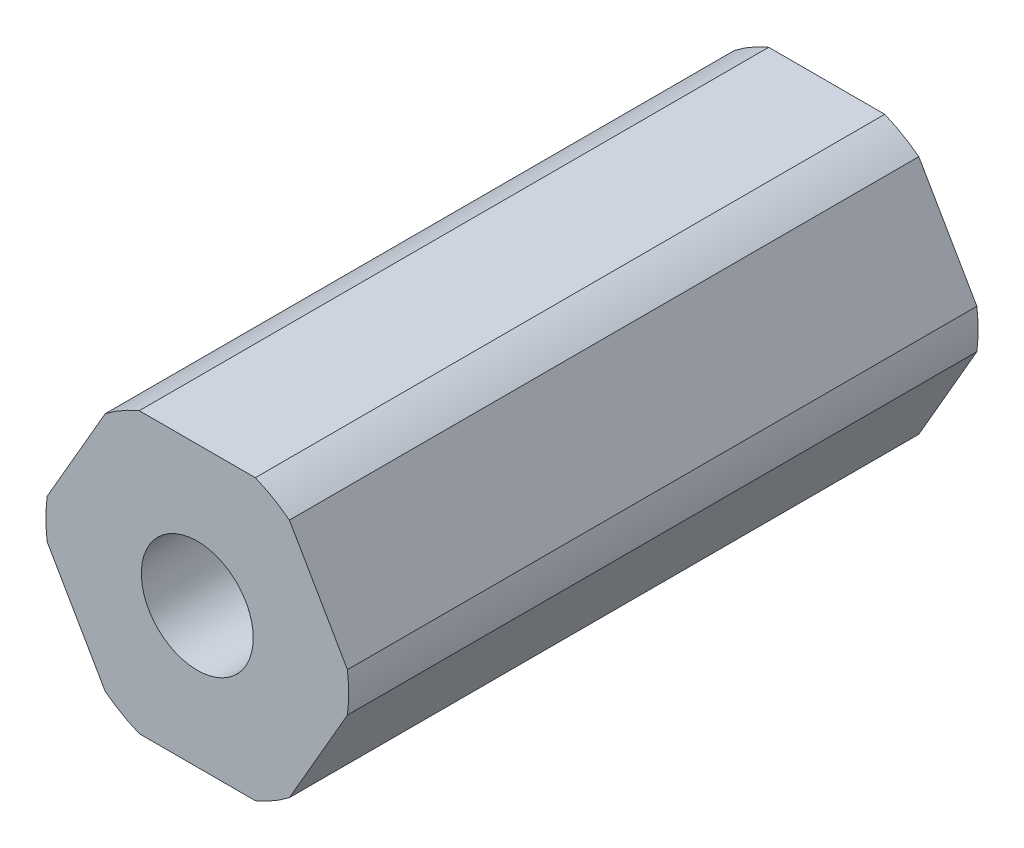
from build123d import *

# Parameters (mm, degrees)
SKETCH1_R           = 2.54
BOSS_EXTRUDE1_DEPTH = 28.575


with BuildPart() as part:
    # Sketch1 → Boss-Extrude1 (new body)
    with BuildSketch(Plane.XY):
        with BuildLine():
            Line((4.181770802, -5.456960506), (6.816751826, -0.893039494))
            ThreePointArc((6.816751826, -0.893039494), (6.875, 0), (6.816751826, 0.893039494))
            Line((6.816751826, 0.893039494), (4.181770802, 5.456960506))
            ThreePointArc((4.181770802, 5.456960506), (3.4375, 5.953924651), (2.634981025, 6.35))
            Line((2.634981025, 6.35), (-2.634981025, 6.35))
            ThreePointArc((-2.634981025, 6.35), (-3.4375, 5.953924651), (-4.181770802, 5.456960506))
            Line((-4.181770802, 5.456960506), (-6.816751826, 0.893039494))
            ThreePointArc((-6.816751826, 0.893039494), (-6.875, 0), (-6.816751826, -0.893039494))
            Line((-6.816751826, -0.893039494), (-4.181770802, -5.456960506))
            ThreePointArc((-4.181770802, -5.456960506), (-3.4375, -5.953924651), (-2.634981025, -6.35))
            Line((-2.634981025, -6.35), (2.634981025, -6.35))
            ThreePointArc((2.634981025, -6.35), (3.4375, -5.953924651), (4.181770802, -5.456960506))
        make_face()
        Circle(SKETCH1_R, mode=Mode.SUBTRACT)
    extrude(amount=BOSS_EXTRUDE1_DEPTH)


solid = part.part
